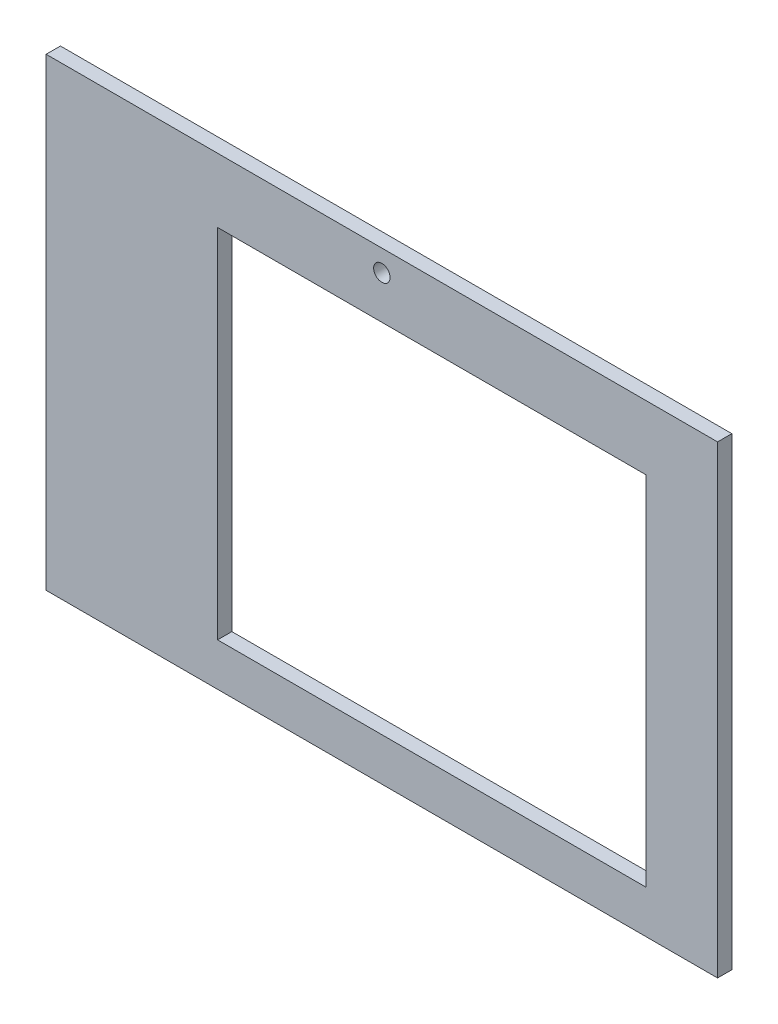
from build123d import *

# Parameters (mm, degrees)
CROQUIS1_W              = 1200
CROQUIS1_H              = 950
SALIENTE_EXTRUIR1_DEPTH = 20
CROQUIS2_W              = 150
CROQUIS2_H              = 180
CORTAR_EXTRUIR1_DEPTH   = 20
CROQUIS3_W              = 600
CROQUIS3_H              = 500
CORTAR_EXTRUIR2_DEPTH   = 20
CROQUIS5_W              = 1200
CROQUIS5_H              = 300
CORTAR_EXTRUIR4_DEPTH   = 40
CROQUIS4_R              = 11.5
CORTAR_EXTRUIR5_DEPTH   = 40
CROQUIS6_W              = 80
CROQUIS6_H              = 650
CROQUIS6_W_2            = 178
CORTAR_EXTRUIR6_DEPTH   = 30
CROQUIS7_W              = 2
CROQUIS7_H              = 650
CORTAR_EXTRUIR7_DEPTH   = 30


with BuildPart() as part:
    # Croquis1 → Saliente-Extruir1 (new body)
    with BuildSketch(Plane.XY):
        Rectangle(CROQUIS1_W, CROQUIS1_H)
    extrude(amount=SALIENTE_EXTRUIR1_DEPTH)

    # Croquis2 → Cortar-Extruir1 (cut)
    with BuildSketch(Plane.XY.offset(20)):
        with Locations((-200, 355)):
            Rectangle(CROQUIS2_W, CROQUIS2_H)
    extrude(amount=-CORTAR_EXTRUIR1_DEPTH, mode=Mode.SUBTRACT)

    # Croquis3 → Cortar-Extruir2 (cut)
    with BuildSketch(Plane(origin=(0, 0, 0), x_dir=(-1, 0, 0), z_dir=(0, 0, -1))):
        with Locations((-120, -165)):
            Rectangle(CROQUIS3_W, CROQUIS3_H)
    extrude(amount=-CORTAR_EXTRUIR2_DEPTH, mode=Mode.SUBTRACT)

    # Croquis5 → Cortar-Extruir4 (cut)
    with BuildSketch(Plane(origin=(0, 0, 0), x_dir=(-1, 0, 0), z_dir=(0, 0, -1))):
        with Locations((0, 325)):
            Rectangle(CROQUIS5_W, CROQUIS5_H)
    extrude(amount=-CORTAR_EXTRUIR4_DEPTH, mode=Mode.SUBTRACT)

    # Croquis4 → Cortar-Extruir5 (cut)
    with BuildSketch(Plane(origin=(0, 0, 0), x_dir=(-1, 0, 0), z_dir=(0, 0, -1))):
        with Locations((-50, 145)):
            Circle(CROQUIS4_R)
    extrude(amount=-CORTAR_EXTRUIR5_DEPTH, mode=Mode.SUBTRACT)

    # Croquis6 → Cortar-Extruir6 (cut)
    with BuildSketch(Plane(origin=(0, 0, 0), x_dir=(-1, 0, 0), z_dir=(0, 0, -1))):
        with Locations((-560, -150)):
            Rectangle(CROQUIS6_W, CROQUIS6_H)
        with Locations((511, -150)):
            Rectangle(CROQUIS6_W_2, CROQUIS6_H)
    extrude(amount=-CORTAR_EXTRUIR6_DEPTH, mode=Mode.SUBTRACT)

    # Croquis7 → Cortar-Extruir7 (cut)
    with BuildSketch(Plane(origin=(0, 0, 0), x_dir=(-1, 0, 0), z_dir=(0, 0, -1))):
        with Locations((421, -150)):
            Rectangle(CROQUIS7_W, CROQUIS7_H)
    extrude(amount=-CORTAR_EXTRUIR7_DEPTH, mode=Mode.SUBTRACT)


solid = part.part
